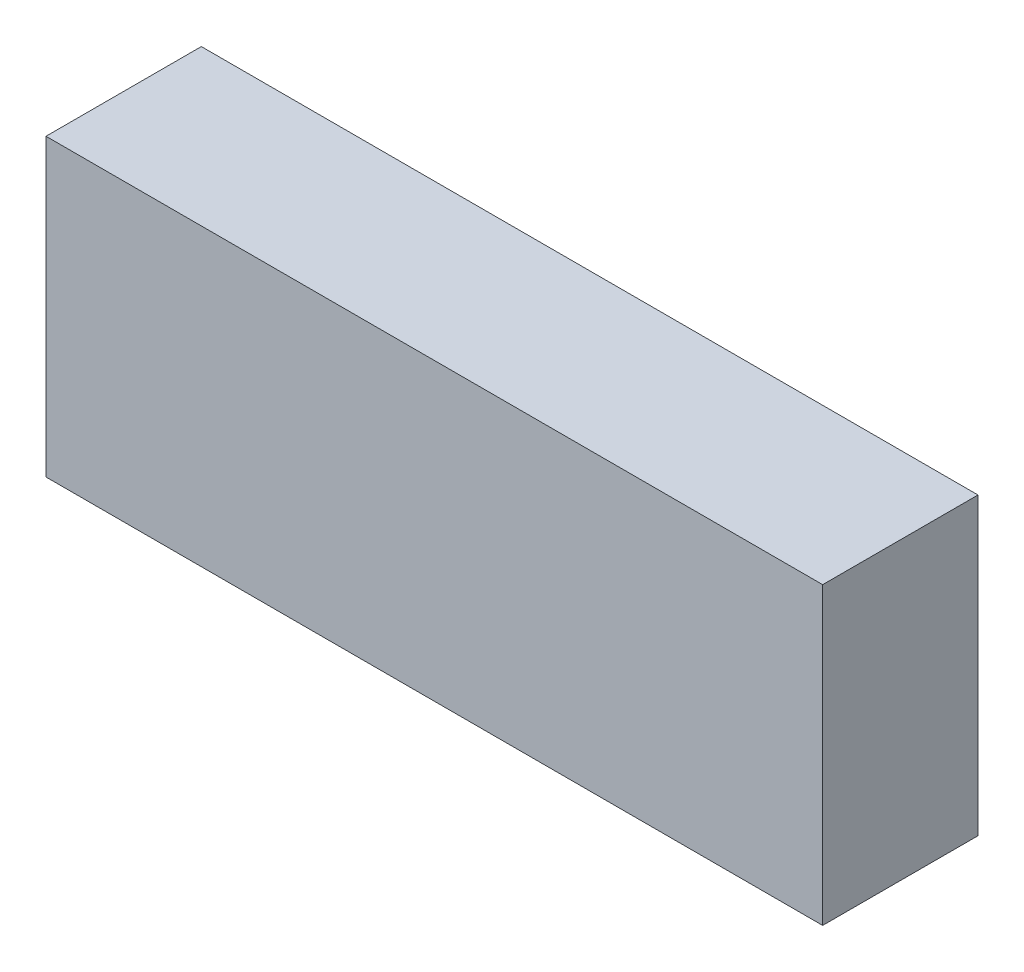
from build123d import *

# Parameters (mm, degrees)
SKETCH1_W           = 50
SKETCH1_H           = 19
BOSS_EXTRUDE1_DEPTH = 10


with BuildPart() as part:
    # Sketch1 → Boss-Extrude1 (new body)
    with BuildSketch(Plane.XY):
        Rectangle(SKETCH1_W, SKETCH1_H)
    extrude(amount=BOSS_EXTRUDE1_DEPTH)


solid = part.part
